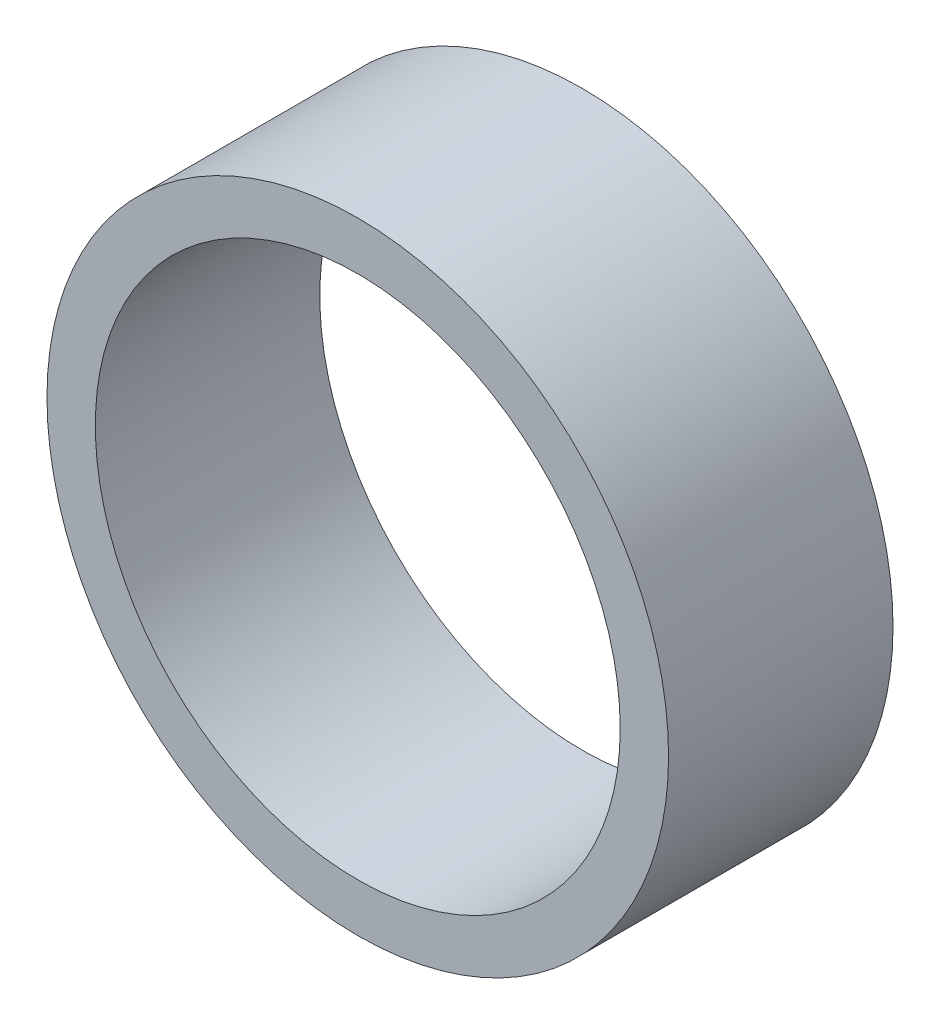
from build123d import *

# Parameters (mm, degrees)
ESQUISSE1_R        = 9
ESQUISSE1_R_2      = 7.6
BOSS_EXTRU_1_DEPTH = 6.5


with BuildPart() as part:
    # Esquisse1 → Boss.-Extru.1 (new body)
    with BuildSketch(Plane.XY):
        Circle(ESQUISSE1_R)
        Circle(ESQUISSE1_R_2, mode=Mode.SUBTRACT)
    extrude(amount=BOSS_EXTRU_1_DEPTH)


solid = part.part
